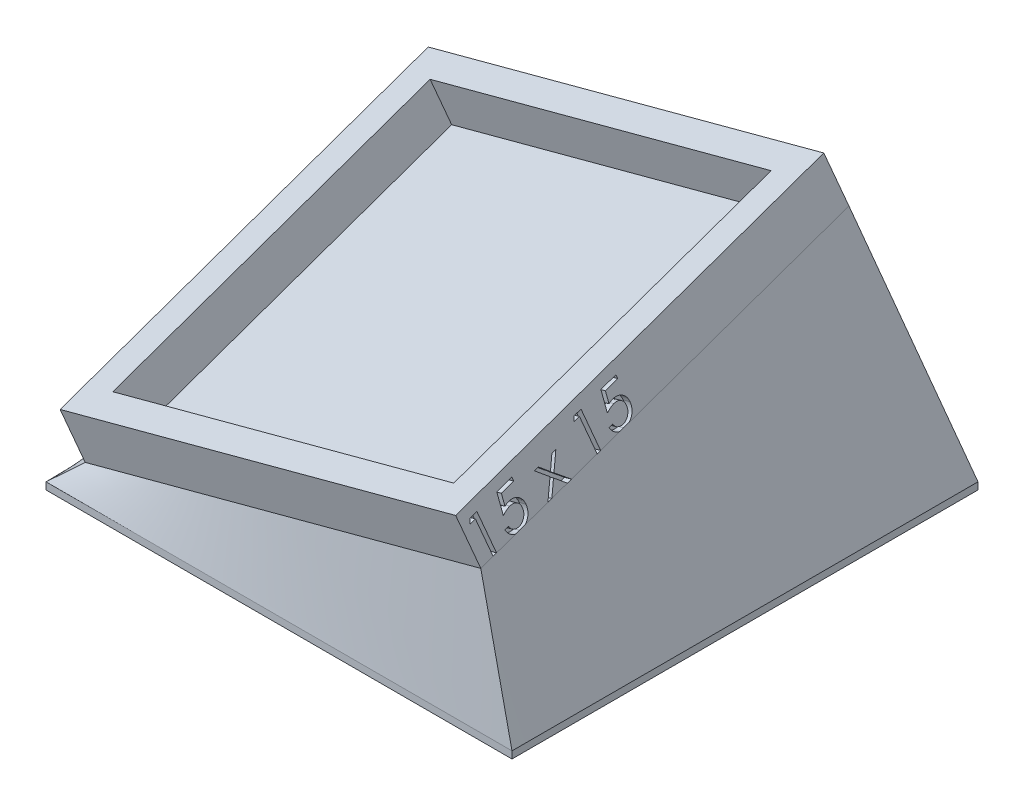
from build123d import *

# Parameters (mm, degrees)
SKETCH1_W             = 36.83
SKETCH1_H             = 36.83
BOSS_EXTRUDE1_DEPTH   = 0.635
SKETCH2_W             = 36.83
SKETCH2_H             = 36.83
SKETCH2_W_2           = 31.75
SKETCH2_H_2           = 31.75
BOSS_EXTRUDE2_DEPTH   = 3.81
SKETCH3_W             = 41.91
SKETCH3_H             = 41.91
BOSS_EXTRUDE3_DEPTH   = 0.635
BODY_MOVE_COPY2_ANGLE = 21.18282227
CUT_EXTRUDE2_DEPTH    = 0.635


with BuildPart() as part:
    # Sketch1 → Boss-Extrude1 (new body)
    with BuildSketch(Plane(origin=(0, 0, 0), x_dir=(1, 0, 0), z_dir=(0, 1, 0))):
        with Locations((-3.873751075, -5.413720286)):
            Rectangle(SKETCH1_W, SKETCH1_H)
    extrude(amount=BOSS_EXTRUDE1_DEPTH)

    # Sketch2 → Boss-Extrude2 (add)
    with BuildSketch(Plane(origin=(0, 0.635, 0), x_dir=(1, 0, 0), z_dir=(0, 1, 0))):
        with Locations((-3.873751075, -5.413720286)):
            Rectangle(SKETCH2_W, SKETCH2_H)
        with Locations((-3.873751075, -5.413720286)):
            Rectangle(SKETCH2_W_2, SKETCH2_H_2, mode=Mode.SUBTRACT)
    extrude(amount=BOSS_EXTRUDE2_DEPTH)


with BuildPart() as part_1:
    # Body-Move/Copy1: moved
    add(part.part.moved(Location((0, 12.7, 0))))


with BuildPart() as body_2:
    # Sketch3 → Boss-Extrude3 (new body)
    with BuildSketch(Plane(origin=(0, 0, 0), x_dir=(1, 0, 0), z_dir=(0, 1, 0))):
        with Locations((-3.873751075, -5.413720286)):
            Rectangle(SKETCH3_W, SKETCH3_H)
    extrude(amount=BOSS_EXTRUDE3_DEPTH)


with BuildPart() as part_2:
    # Body-Move/Copy2: moved
    add(part_1.part.moved(Location((0, 0, 0))).rotate(Axis((-4.947924202, 4.621082425, 4.339547159), (0.7040625922196356, 0.09269159872357148, 0.7040625922196375)), BODY_MOVE_COPY2_ANGLE))


    add(body_2.part)  # loft1 joins it to this body
    # loft from a face of the part (loft1)
    loft([part_2.faces().sort_by_distance((-5.858126075, 12.168288321, 7.468096456))[0], part_2.faces().sort_by_distance((-3.873751075, 0.635, 5.413720286))[0]])

    # Sketch5 → Cut-Extrude2 (cut)
    with BuildSketch(Plane(origin=(15.363890134, 4.116741954, 0), x_dir=(0, 0, -1), z_dir=(0.9659258262890681, 0.25881904510252135, 0))):
        Polygon((-25.289975515, 12.087139326), (-24.63162215, 12.263822018), (-23.733485131, 8.911758717), (-24.065816862, 8.822716249), (-24.876313656, 11.84665455), (-25.402856124, 11.705027948), align=None)
        with BuildLine():
            Line((-21.2584164, 13.167473454), (-21.172879541, 12.848463037))
            Line((-21.172879541, 12.848463037), (-22.366889957, 12.528751499))
            Line((-22.366889957, 12.528751499), (-22.288364316, 11.570318005))
            add(Edge.make_bspline(
                [(-22.288364316, 11.570318005), (-22.255434308, 11.589724715), (-22.191784443, 11.62723562), (-22.095235179, 11.673927097), (-22.002884698, 11.712913073), (-21.941027504, 11.731172986), (-21.911160791, 11.73998948)],
                knots=[0, 0, 0, 0, 1.105042412, 2.135918042, 3.099959174, 4, 4, 4, 4], degree=3))
            add(Edge.make_bspline(
                [(-21.911160791, 11.73998948), (-21.8734474, 11.749168338), (-21.799541185, 11.767155974), (-21.688120085, 11.780669788), (-21.579426371, 11.78479657), (-21.473010564, 11.776748725), (-21.368818689, 11.758768067), (-21.26721684, 11.729119902), (-21.168594296, 11.687811043), (-21.072808417, 11.637003644), (-20.982578557, 11.576381811), (-20.898733043, 11.50804589), (-20.823772694, 11.430822575), (-20.75489396, 11.3469314), (-20.696592615, 11.253325609), (-20.644126495, 11.153300852), (-20.59962398, 11.045168075), (-20.577617375, 10.968991373), (-20.566409188, 10.930193807)],
                knots=[0, 0, 0, 0, 1.05801573, 2.073373342, 3.055708438, 4.020950882, 4.978965477, 5.935281463, 6.90140781, 7.89110117, 8.888383828, 9.862241404, 10.836036372, 11.819777286, 12.817284082, 13.838151086, 14.898948423, 16, 16, 16, 16], degree=3))
            add(Edge.make_bspline(
                [(-20.566409188, 10.930193807), (-20.553819554, 10.875746681), (-20.528961553, 10.768241832), (-20.515841863, 10.604056683), (-20.524447154, 10.441733939), (-20.548645308, 10.308887337), (-20.57714438, 10.20550713), (-20.604139504, 10.130964068), (-20.634817824, 10.059441182), (-20.670001461, 9.990909131), (-20.71018021, 9.925759109), (-20.754234922, 9.863303001), (-20.802744558, 9.804032051), (-20.856198771, 9.748729729), (-20.913731753, 9.696886004), (-20.974935264, 9.64855756), (-21.039213532, 9.603078293), (-21.108702877, 9.56380266), (-21.180549097, 9.525805982), (-21.257438146, 9.494229783), (-21.337350491, 9.465106215), (-21.392462722, 9.449111827), (-21.420375534, 9.441011114)],
                knots=[0, 0, 0, 0, 1.741238918, 3.438044251, 5.116889302, 6.798359255, 7.638446169, 8.459274067, 9.269022397, 10.06450398, 10.859618097, 11.654464858, 12.446867837, 13.245948299, 14.051090142, 14.860510307, 15.677444928, 16.503853352, 17.348230314, 18.210632726, 19.093735256, 20, 20, 20, 20], degree=3))
            add(Edge.make_bspline(
                [(-21.420375534, 9.441011114), (-21.453904357, 9.4326917), (-21.51997898, 9.416296786), (-21.619561723, 9.402550347), (-21.717146908, 9.397575625), (-21.812916692, 9.400892358), (-21.906910361, 9.413365485), (-21.998768235, 9.435643129), (-22.088871416, 9.465570172), (-22.176171959, 9.505095735), (-22.259843198, 9.551539193), (-22.338021497, 9.60530411), (-22.410899851, 9.664764729), (-22.476465858, 9.732228872), (-22.538318336, 9.804270967), (-22.59283333, 9.884292953), (-22.64218421, 9.97021365), (-22.6693642, 10.031328833), (-22.683095887, 10.062205024)],
                knots=[0, 0, 0, 0, 1.072682092, 2.11391456, 3.117214971, 4.105372355, 5.087079608, 6.057470674, 7.037915073, 8.032454251, 9.030380365, 10.007161351, 10.976818682, 11.947209748, 12.926174271, 13.923148972, 14.950747652, 16, 16, 16, 16], degree=3))
            Line((-22.683095887, 10.062205024), (-22.338845086, 10.154753101))
            add(Edge.make_bspline(
                [(-22.338845086, 10.154753101), (-22.323494717, 10.125696187), (-22.293997088, 10.069859735), (-22.242473312, 9.993816681), (-22.186194452, 9.929127176), (-22.125969488, 9.873817573), (-22.059512627, 9.82883435), (-21.986811088, 9.793786916), (-21.908962365, 9.764120646), (-21.825514667, 9.74451835), (-21.73950451, 9.73310344), (-21.653013104, 9.732057964), (-21.567233359, 9.738974965), (-21.511401647, 9.752069727), (-21.483476496, 9.758619287)],
                knots=[0, 0, 0, 0, 1.149724663, 2.209337986, 3.20668241, 4.144905754, 5.063814906, 6.004033259, 6.964357036, 7.974270233, 8.997055795, 9.99520507, 10.997268736, 12, 12, 12, 12], degree=3))
            add(Edge.make_bspline(
                [(-21.483476496, 9.758619287), (-21.456678837, 9.766808462), (-21.403634844, 9.783018331), (-21.327561599, 9.815088192), (-21.257063028, 9.855561977), (-21.191720643, 9.902545357), (-21.131367013, 9.956631117), (-21.075923939, 10.017550737), (-21.02615408, 10.086241904), (-20.981356475, 10.160647797), (-20.94424806, 10.240040219), (-20.91322831, 10.321568073), (-20.892680618, 10.405706565), (-20.878834233, 10.491263788), (-20.874880167, 10.57895924), (-20.87953206, 10.668271033), (-20.890812272, 10.759978835), (-20.905815855, 10.820708841), (-20.913464477, 10.851668165)],
                knots=[0, 0, 0, 0, 0.979310761, 1.938473547, 2.878974548, 3.815527507, 4.747184592, 5.707390891, 6.689594749, 7.708334083, 8.739028911, 9.749873472, 10.752627963, 11.761489178, 12.775861083, 13.814717594, 14.885972978, 16, 16, 16, 16], degree=3))
            add(Edge.make_bspline(
                [(-20.913464477, 10.851668165), (-20.921710321, 10.87914071), (-20.937854914, 10.93292939), (-20.968394115, 11.009877213), (-21.006351774, 11.080175922), (-21.047888211, 11.145997366), (-21.096605573, 11.205137908), (-21.151298736, 11.257723467), (-21.210157027, 11.306213723), (-21.275243581, 11.346967722), (-21.344251788, 11.381529395), (-21.416244311, 11.409051456), (-21.491344627, 11.42798982), (-21.568870005, 11.439135311), (-21.649228909, 11.442866048), (-21.732209592, 11.437150307), (-21.818243602, 11.425897908), (-21.875519212, 11.411516844), (-21.904850695, 11.40415214)],
                knots=[0, 0, 0, 0, 1.076677971, 2.108035064, 3.101059175, 4.072133559, 5.025930222, 5.96905328, 6.917304919, 7.883650759, 8.845004594, 9.811350433, 10.771101343, 11.74640787, 12.74761596, 13.784778949, 14.865560468, 16, 16, 16, 16], degree=3))
            add(Edge.make_bspline(
                [(-21.904850695, 11.40415214), (-21.929982666, 11.396814252), (-21.981832231, 11.381675517), (-22.05933718, 11.350950765), (-22.139371021, 11.314455955), (-22.221749803, 11.271391484), (-22.306618642, 11.221448381), (-22.393913432, 11.164572351), (-22.484005759, 11.101572057), (-22.543303223, 11.055493344), (-22.573720887, 11.031856467)],
                knots=[0, 0, 0, 0, 0.815255253, 1.681946475, 2.59422888, 3.554909121, 4.576352004, 5.660825586, 6.800079838, 8, 8, 8, 8], degree=3))
            Line((-22.573720887, 11.031856467), (-22.709738515, 12.778350858))
            Line((-22.709738515, 12.778350858), (-21.2584164, 13.167473454))
        make_face()
        Polygon((-19.34524239, 12.744555175), (-18.96242989, 12.846918957), (-18.06008614, 12.104430976), (-17.64992989, 13.198882098), (-17.26711739, 13.30124588), (-17.799268832, 11.896197803), (-16.495883415, 10.850825207), (-16.883603768, 10.747059181), (-17.921264024, 11.584899726), (-18.389613383, 10.343213027), (-18.770322518, 10.241550367), (-18.179977967, 11.794535143), align=None)
        Polygon((-15.23443999, 14.781511949), (-14.576086625, 14.958194642), (-13.677949606, 11.606131341), (-14.010281337, 11.517088873), (-14.820778131, 14.541027174), (-15.347320599, 14.399400571), align=None)
        with BuildLine():
            Line((-11.202880875, 15.861846077), (-11.117344016, 15.542835661))
            Line((-11.117344016, 15.542835661), (-12.311354432, 15.223124122))
            Line((-12.311354432, 15.223124122), (-12.232828791, 14.264690629))
            add(Edge.make_bspline(
                [(-12.232828791, 14.264690629), (-12.199898783, 14.284097338), (-12.136248918, 14.321608243), (-12.039699654, 14.36829972), (-11.947349173, 14.407285696), (-11.885491979, 14.425545609), (-11.855625266, 14.434362103)],
                knots=[0, 0, 0, 0, 1.105042412, 2.135918042, 3.099959174, 4, 4, 4, 4], degree=3))
            add(Edge.make_bspline(
                [(-11.855625266, 14.434362103), (-11.817911875, 14.443540962), (-11.74400566, 14.461528597), (-11.63258456, 14.475042412), (-11.523890846, 14.479169193), (-11.417475039, 14.471121349), (-11.313283164, 14.45314069), (-11.211681315, 14.423492526), (-11.113058771, 14.382183666), (-11.017272892, 14.331376268), (-10.927043032, 14.270754434), (-10.843197518, 14.202418513), (-10.768237169, 14.125195198), (-10.699358435, 14.041304023), (-10.64105709, 13.947698232), (-10.58859097, 13.847673475), (-10.544088455, 13.739540698), (-10.52208185, 13.663363997), (-10.510873663, 13.62456643)],
                knots=[0, 0, 0, 0, 1.05801573, 2.073373342, 3.055708438, 4.020950882, 4.978965477, 5.935281463, 6.90140781, 7.89110117, 8.888383828, 9.862241404, 10.836036372, 11.819777286, 12.817284082, 13.838151086, 14.898948423, 16, 16, 16, 16], degree=3))
            add(Edge.make_bspline(
                [(-10.510873663, 13.62456643), (-10.498284029, 13.570119304), (-10.473426028, 13.462614455), (-10.460306338, 13.298429306), (-10.468911629, 13.136106563), (-10.493109783, 13.003259961), (-10.521608855, 12.899879753), (-10.548603979, 12.825336691), (-10.579282299, 12.753813805), (-10.614465936, 12.685281755), (-10.654644685, 12.620131732), (-10.698699397, 12.557675624), (-10.747209033, 12.498404674), (-10.800663246, 12.443102353), (-10.858196228, 12.391258627), (-10.919399739, 12.342930183), (-10.983678007, 12.297450916), (-11.053167352, 12.258175283), (-11.125013572, 12.220178605), (-11.201902622, 12.188602407), (-11.281814966, 12.159478839), (-11.336927197, 12.14348445), (-11.364840009, 12.135383738)],
                knots=[0, 0, 0, 0, 1.741238918, 3.438044251, 5.116889302, 6.798359255, 7.638446169, 8.459274067, 9.269022397, 10.06450398, 10.859618097, 11.654464858, 12.446867837, 13.245948299, 14.051090142, 14.860510307, 15.677444928, 16.503853352, 17.348230314, 18.210632726, 19.093735256, 20, 20, 20, 20], degree=3))
            add(Edge.make_bspline(
                [(-11.364840009, 12.135383738), (-11.398368832, 12.127064323), (-11.464443456, 12.110669409), (-11.564026198, 12.09692297), (-11.661611383, 12.091948248), (-11.757381167, 12.095264981), (-11.851374836, 12.107738109), (-11.94323271, 12.130015752), (-12.033335891, 12.159942795), (-12.120636434, 12.199468358), (-12.204307673, 12.245911816), (-12.282485972, 12.299676733), (-12.355364326, 12.359137352), (-12.420930333, 12.426601495), (-12.482782811, 12.498643591), (-12.537297805, 12.578665577), (-12.586648685, 12.664586273), (-12.613828675, 12.725701456), (-12.627560362, 12.756577648)],
                knots=[0, 0, 0, 0, 1.072682092, 2.11391456, 3.117214971, 4.105372355, 5.087079608, 6.057470674, 7.037915073, 8.032454251, 9.030380365, 10.007161351, 10.976818682, 11.947209748, 12.926174271, 13.923148972, 14.950747652, 16, 16, 16, 16], degree=3))
            Line((-12.627560362, 12.756577648), (-12.283309561, 12.849125725))
            add(Edge.make_bspline(
                [(-12.283309561, 12.849125725), (-12.267959192, 12.82006881), (-12.238461563, 12.764232358), (-12.186937787, 12.688189305), (-12.130658927, 12.623499799), (-12.070433964, 12.568190196), (-12.003977103, 12.523206973), (-11.931275564, 12.488159539), (-11.85342684, 12.45849327), (-11.769979142, 12.438890974), (-11.683968986, 12.427476063), (-11.597477579, 12.426430588), (-11.511697834, 12.433347589), (-11.455866123, 12.44644235), (-11.427940971, 12.452991911)],
                knots=[0, 0, 0, 0, 1.149724663, 2.209337986, 3.20668241, 4.144905754, 5.063814906, 6.004033259, 6.964357036, 7.974270233, 8.997055795, 9.99520507, 10.997268736, 12, 12, 12, 12], degree=3))
            add(Edge.make_bspline(
                [(-11.427940971, 12.452991911), (-11.401143312, 12.461181086), (-11.348099319, 12.477390954), (-11.272026074, 12.509460815), (-11.201527503, 12.549934601), (-11.136185118, 12.59691798), (-11.075831488, 12.65100374), (-11.020388414, 12.711923361), (-10.970618555, 12.780614527), (-10.92582095, 12.85502042), (-10.888712535, 12.934412842), (-10.857692785, 13.015940697), (-10.837145093, 13.100079188), (-10.823298708, 13.185636411), (-10.819344642, 13.273331864), (-10.823996535, 13.362643656), (-10.835276747, 13.454351458), (-10.85028033, 13.515081464), (-10.857928952, 13.546040789)],
                knots=[0, 0, 0, 0, 0.979310761, 1.938473547, 2.878974548, 3.815527507, 4.747184592, 5.707390891, 6.689594749, 7.708334083, 8.739028911, 9.749873472, 10.752627963, 11.761489178, 12.775861083, 13.814717594, 14.885972978, 16, 16, 16, 16], degree=3))
            add(Edge.make_bspline(
                [(-10.857928952, 13.546040789), (-10.866174796, 13.573513333), (-10.882319389, 13.627302014), (-10.91285859, 13.704249836), (-10.950816249, 13.774548546), (-10.992352686, 13.840369989), (-11.041070048, 13.899510531), (-11.095763211, 13.952096091), (-11.154621502, 14.000586346), (-11.219708056, 14.041340345), (-11.288716263, 14.075902018), (-11.360708786, 14.103424079), (-11.435809102, 14.122362443), (-11.51333448, 14.133507934), (-11.593693384, 14.137238671), (-11.676674067, 14.131522931), (-11.762708077, 14.120270532), (-11.819983688, 14.105889467), (-11.84931517, 14.098524763)],
                knots=[0, 0, 0, 0, 1.076677971, 2.108035064, 3.101059175, 4.072133559, 5.025930222, 5.96905328, 6.917304919, 7.883650759, 8.845004594, 9.811350433, 10.771101343, 11.74640787, 12.74761596, 13.784778949, 14.865560468, 16, 16, 16, 16], degree=3))
            add(Edge.make_bspline(
                [(-11.84931517, 14.098524763), (-11.874447141, 14.091186876), (-11.926296706, 14.07604814), (-12.003801655, 14.045323388), (-12.083835496, 14.008828578), (-12.166214278, 13.965764107), (-12.251083117, 13.915821004), (-12.338377907, 13.858944974), (-12.428470234, 13.795944681), (-12.487767698, 13.749865967), (-12.518185362, 13.72622909)],
                knots=[0, 0, 0, 0, 0.815255253, 1.681946475, 2.59422888, 3.554909121, 4.576352004, 5.660825586, 6.800079838, 8, 8, 8, 8], degree=3))
            Line((-12.518185362, 13.72622909), (-12.65420299, 15.472723481))
            Line((-12.65420299, 15.472723481), (-11.202880875, 15.861846077))
        make_face()
    extrude(amount=-CUT_EXTRUDE2_DEPTH, mode=Mode.SUBTRACT)


solid = part_2.part
